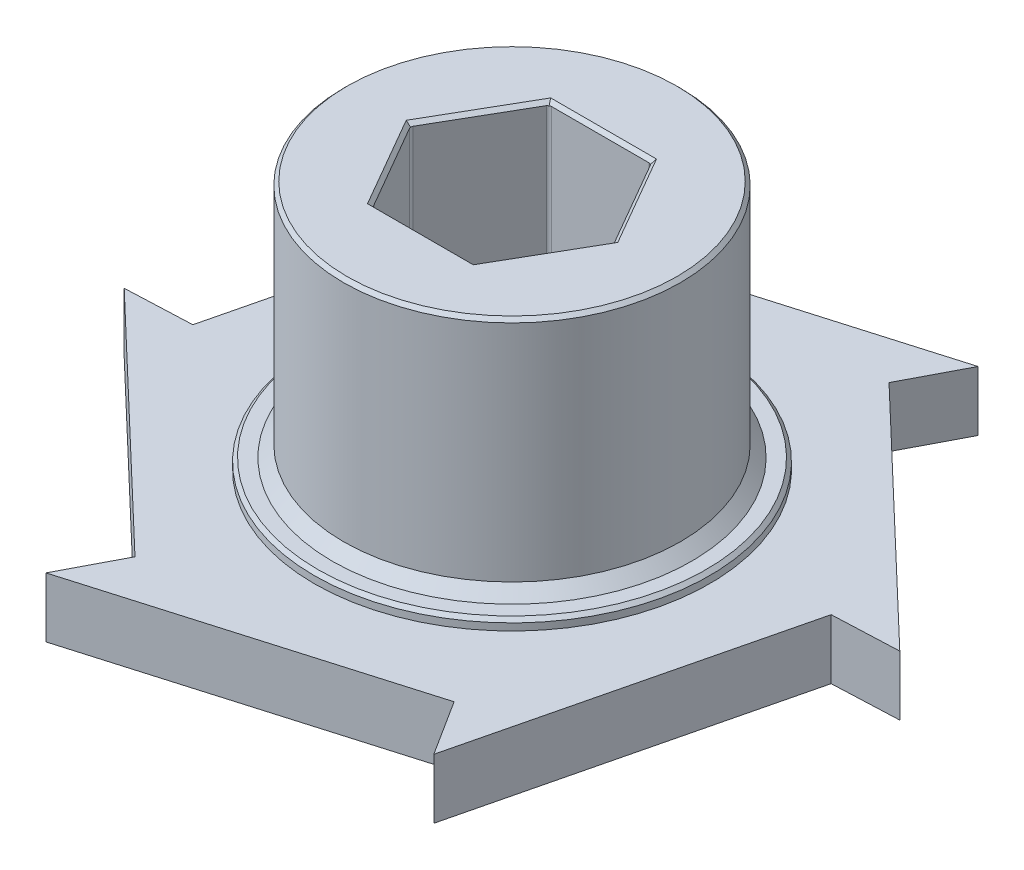
from build123d import *

# Parameters (mm, degrees)
SKETCH1_W           = 27.7876
SKETCH1_H           = 4.318
CUT_EXTRUDE1_DEPTH  = 5.318
CUT_EXTRUDE2_DEPTH  = 5.318
CUT_EXTRUDE3_DEPTH  = 5.318
CUT_EXTRUDE4_DEPTH  = 5.318
CUT_EXTRUDE5_DEPTH  = 5.318
CUT_EXTRUDE6_DEPTH  = 5.318
CUT_EXTRUDE7_DEPTH  = 5.318
CUT_EXTRUDE8_DEPTH  = 5.318
CUT_EXTRUDE9_DEPTH  = 5.318
CUT_EXTRUDE10_DEPTH = 5.318
CUT_EXTRUDE11_DEPTH = 5.318
CUT_EXTRUDE12_DEPTH = 5.318
SKETCH14_R          = 14.2748
BOSS_EXTRUDE1_DEPTH = 1.524
SKETCH15_R          = 9.23823544
BOSS_EXTRUDE2_DEPTH = 1.524
SKETCH16_R          = 14.2748
BOSS_EXTRUDE3_DEPTH = 0.762
SKETCH17_R          = 12.1666
BOSS_EXTRUDE4_DEPTH = 17.272
CUT_EXTRUDE13_DEPTH = 26.4
SKETCH19_W          = 2.5908
SKETCH19_H          = 4.318
SKETCH20_W          = 2.5908
SKETCH20_H          = 4.318
SKETCH21_W          = 2.5908
SKETCH21_H          = 4.318
SKETCH22_W          = 2.5908
SKETCH22_H          = 4.318
SKETCH23_W          = 2.5908
SKETCH23_H          = 4.318
SKETCH24_W          = 2.5908
SKETCH24_H          = 4.318
CHAMFER1_SIZE       = 0.254
CHAMFER2_SIZE       = 0.8128
FILLET1_R           = 0.254
FILLET2_R           = 0.7874
FILLET3_R           = 1.27
SKETCH25_R          = 28.050561638
SKETCH25_R_2        = 25.4889
CUT_EXTRUDE14_DEPTH = 8.366
CUT_EXTRUDE15_DEPTH = 8.366


with BuildPart() as part:
    # Sketch1 → Revolve1 (revolve)
    with BuildSketch(Plane.XY):
        with Locations((13.8938, 5.207)):
            Rectangle(SKETCH1_W, SKETCH1_H)
    revolve(axis=Axis((0, 7.366, 0), (0, -1, 0)))

    # Sketch2 → Cut-Extrude1 (cut, through all)
    with BuildSketch(Plane(origin=(0, 7.366, 0), x_dir=(-1, 0, 0), z_dir=(0, 1, 0))):
        with BuildLine():
            Line((27.742216161, 1.5875), (25.859959008, 1.5875))
            ThreePointArc((25.859959008, 1.5875), (26.4033, 0), (25.859959008, -1.5875))
            Line((25.859959008, -1.5875), (27.742216161, -1.5875))
            ThreePointArc((27.742216161, -1.5875), (27.7876, 0), (27.742216161, 1.5875))
        make_face()
    extrude(amount=-CUT_EXTRUDE1_DEPTH, mode=Mode.SUBTRACT)

    # Sketch3 → Cut-Extrude2 (cut, through all)
    with BuildSketch(Plane(origin=(0, 7.366, 0), x_dir=(-1, 0, 0), z_dir=(0, 1, 0))):
        with BuildLine():
            ThreePointArc((27.521980347, -3.832924674), (26.332306318, -4.701290474), (24.95050128, -5.211190755))
            ThreePointArc((24.95050128, -5.211190755), (22.074034915, -12.74445), (16.988274218, -19.002172568))
            ThreePointArc((16.988274218, -19.002172568), (17.23759014, -20.453800974), (17.080400312, -21.918271806))
            ThreePointArc((17.080400312, -21.918271806), (24.06476751, -13.8938), (27.521980347, -3.832924674))
        make_face()
    extrude(amount=-CUT_EXTRUDE2_DEPTH, mode=Mode.SUBTRACT)

    # Sketch4 → Cut-Extrude3 (cut, through all)
    with BuildSketch(Plane(origin=(0, 7.366, 0), x_dir=(-1, 0, 0), z_dir=(0, 1, 0))):
        with BuildLine():
            Line((15.245923409, -23.231713952), (14.304794833, -21.601631442))
            ThreePointArc((14.304794833, -21.601631442), (13.20165, -22.865928544), (11.555164176, -23.189131442))
            Line((11.555164176, -23.189131442), (12.496292752, -24.819213952))
            ThreePointArc((12.496292752, -24.819213952), (13.8938, -24.06476751), (15.245923409, -23.231713952))
        make_face()
    extrude(amount=-CUT_EXTRUDE3_DEPTH, mode=Mode.SUBTRACT)

    # Sketch5 → Cut-Extrude4 (cut, through all)
    with BuildSketch(Plane(origin=(0, 7.366, 0), x_dir=(-1, 0, 0), z_dir=(0, 1, 0))):
        with BuildLine():
            ThreePointArc((10.441580035, -25.75119648), (9.094716178, -25.155091448), (7.962227062, -24.213363323))
            ThreePointArc((7.962227062, -24.213363323), (0, -25.4889), (-7.962227062, -24.213363323))
            ThreePointArc((-7.962227062, -24.213363323), (-9.094716178, -25.155091448), (-10.441580035, -25.75119648))
            ThreePointArc((-10.441580035, -25.75119648), (0, -27.7876), (10.441580035, -25.75119648))
        make_face()
    extrude(amount=-CUT_EXTRUDE4_DEPTH, mode=Mode.SUBTRACT)

    # Sketch6 → Cut-Extrude5 (cut, through all)
    with BuildSketch(Plane(origin=(0, 7.366, 0), x_dir=(-1, 0, 0), z_dir=(0, 1, 0))):
        with BuildLine():
            Line((-12.496292752, -24.819213952), (-11.555164176, -23.189131442))
            ThreePointArc((-11.555164176, -23.189131442), (-13.20165, -22.865928544), (-14.304794833, -21.601631442))
            Line((-14.304794833, -21.601631442), (-15.245923409, -23.231713952))
            ThreePointArc((-15.245923409, -23.231713952), (-13.8938, -24.06476751), (-12.496292752, -24.819213952))
        make_face()
    extrude(amount=-CUT_EXTRUDE5_DEPTH, mode=Mode.SUBTRACT)

    # Sketch7 → Cut-Extrude6 (cut, through all)
    with BuildSketch(Plane(origin=(0, 7.366, 0), x_dir=(-1, 0, 0), z_dir=(0, 1, 0))):
        with BuildLine():
            ThreePointArc((-17.080400312, -21.918271806), (-17.23759014, -20.453800974), (-16.988274218, -19.002172568))
            ThreePointArc((-16.988274218, -19.002172568), (-22.074034915, -12.74445), (-24.95050128, -5.211190755))
            ThreePointArc((-24.95050128, -5.211190755), (-26.332306318, -4.701290474), (-27.521980347, -3.832924674))
            ThreePointArc((-27.521980347, -3.832924674), (-24.06476751, -13.8938), (-17.080400312, -21.918271806))
        make_face()
    extrude(amount=-CUT_EXTRUDE6_DEPTH, mode=Mode.SUBTRACT)

    # Sketch8 → Cut-Extrude7 (cut, through all)
    with BuildSketch(Plane(origin=(0, 7.366, 0), x_dir=(-1, 0, 0), z_dir=(0, 1, 0))):
        with BuildLine():
            Line((-27.742216161, -1.5875), (-25.859959008, -1.5875))
            ThreePointArc((-25.859959008, -1.5875), (-26.4033, 0), (-25.859959008, 1.5875))
            Line((-25.859959008, 1.5875), (-27.742216161, 1.5875))
            ThreePointArc((-27.742216161, 1.5875), (-27.7876, 0), (-27.742216161, -1.5875))
        make_face()
    extrude(amount=-CUT_EXTRUDE7_DEPTH, mode=Mode.SUBTRACT)

    # Sketch9 → Cut-Extrude8 (cut, through all)
    with BuildSketch(Plane(origin=(0, 7.366, 0), x_dir=(-1, 0, 0), z_dir=(0, 1, 0))):
        with BuildLine():
            ThreePointArc((-27.521980347, 3.832924674), (-26.332306318, 4.701290474), (-24.95050128, 5.211190755))
            ThreePointArc((-24.95050128, 5.211190755), (-22.074034915, 12.74445), (-16.988274218, 19.002172568))
            ThreePointArc((-16.988274218, 19.002172568), (-17.23759014, 20.453800974), (-17.080400312, 21.918271806))
            ThreePointArc((-17.080400312, 21.918271806), (-24.06476751, 13.8938), (-27.521980347, 3.832924674))
        make_face()
    extrude(amount=-CUT_EXTRUDE8_DEPTH, mode=Mode.SUBTRACT)

    # Sketch10 → Cut-Extrude9 (cut, through all)
    with BuildSketch(Plane(origin=(0, 7.366, 0), x_dir=(-1, 0, 0), z_dir=(0, 1, 0))):
        with BuildLine():
            Line((-15.245923409, 23.231713952), (-14.304794833, 21.601631442))
            ThreePointArc((-14.304794833, 21.601631442), (-13.20165, 22.865928544), (-11.555164176, 23.189131442))
            Line((-11.555164176, 23.189131442), (-12.496292752, 24.819213952))
            ThreePointArc((-12.496292752, 24.819213952), (-13.8938, 24.06476751), (-15.245923409, 23.231713952))
        make_face()
    extrude(amount=-CUT_EXTRUDE9_DEPTH, mode=Mode.SUBTRACT)

    # Sketch11 → Cut-Extrude10 (cut, through all)
    with BuildSketch(Plane(origin=(0, 7.366, 0), x_dir=(-1, 0, 0), z_dir=(0, 1, 0))):
        with BuildLine():
            ThreePointArc((-10.441580035, 25.75119648), (-9.094716178, 25.155091448), (-7.962227062, 24.213363323))
            ThreePointArc((-7.962227062, 24.213363323), (0, 25.4889), (7.962227062, 24.213363323))
            ThreePointArc((7.962227062, 24.213363323), (9.094716178, 25.155091448), (10.441580035, 25.75119648))
            ThreePointArc((10.441580035, 25.75119648), (0, 27.7876), (-10.441580035, 25.75119648))
        make_face()
    extrude(amount=-CUT_EXTRUDE10_DEPTH, mode=Mode.SUBTRACT)

    # Sketch12 → Cut-Extrude11 (cut, through all)
    with BuildSketch(Plane(origin=(0, 7.366, 0), x_dir=(-1, 0, 0), z_dir=(0, 1, 0))):
        with BuildLine():
            Line((12.496292752, 24.819213952), (11.555164176, 23.189131442))
            ThreePointArc((11.555164176, 23.189131442), (13.20165, 22.865928544), (14.304794833, 21.601631442))
            Line((14.304794833, 21.601631442), (15.245923409, 23.231713952))
            ThreePointArc((15.245923409, 23.231713952), (13.8938, 24.06476751), (12.496292752, 24.819213952))
        make_face()
    extrude(amount=-CUT_EXTRUDE11_DEPTH, mode=Mode.SUBTRACT)

    # Sketch13 → Cut-Extrude12 (cut, through all)
    with BuildSketch(Plane(origin=(0, 7.366, 0), x_dir=(-1, 0, 0), z_dir=(0, 1, 0))):
        with BuildLine():
            ThreePointArc((17.080400312, 21.918271806), (17.23759014, 20.453800974), (16.988274218, 19.002172568))
            ThreePointArc((16.988274218, 19.002172568), (22.074034915, 12.74445), (24.95050128, 5.211190755))
            ThreePointArc((24.95050128, 5.211190755), (26.332306318, 4.701290474), (27.521980347, 3.832924674))
            ThreePointArc((27.521980347, 3.832924674), (24.06476751, 13.8938), (17.080400312, 21.918271806))
        make_face()
    extrude(amount=-CUT_EXTRUDE12_DEPTH, mode=Mode.SUBTRACT)

    # Sketch14 → Boss-Extrude1 (add)
    with BuildSketch(Plane.XZ.offset(-3.048)):
        Circle(SKETCH14_R)
    extrude(amount=BOSS_EXTRUDE1_DEPTH)

    # Sketch15 → Boss-Extrude2 (add)
    with BuildSketch(Plane.XZ.offset(-1.524)):
        Circle(SKETCH15_R)
    extrude(amount=BOSS_EXTRUDE2_DEPTH)

    # Sketch16 → Boss-Extrude3 (add)
    with BuildSketch(Plane(origin=(0, 7.366, 0), x_dir=(-1, 0, 0), z_dir=(0, 1, 0))):
        Circle(SKETCH16_R)
    extrude(amount=BOSS_EXTRUDE3_DEPTH)

    # Sketch17 → Boss-Extrude4 (add)
    with BuildSketch(Plane(origin=(0, 8.128, 0), x_dir=(-1, 0, 0), z_dir=(0, 1, 0))):
        Circle(SKETCH17_R)
    extrude(amount=BOSS_EXTRUDE4_DEPTH)

    # Sketch18 → Cut-Extrude13 (cut, through all)
    with BuildSketch(Plane(origin=(0, 25.4, 0), x_dir=(-1, 0, 0), z_dir=(0, 1, 0))):
        Polygon((-3.673506558, -6.3627), (3.673506558, -6.3627), (7.347013116, 0), (3.673506558, 6.3627), (-3.673506558, 6.3627), (-7.347013116, 0), align=None)
    extrude(amount=-CUT_EXTRUDE13_DEPTH, mode=Mode.SUBTRACT)

    # Sketch19 → Cut-Revolve1 (revolve, cut)
    with BuildSketch(Plane(origin=(0, 0, 0), x_dir=(-1, 0, 0), z_dir=(0, 0, -1))):
        with Locations((22.5171, 5.207)):
            Rectangle(SKETCH19_W, SKETCH19_H)
    revolve(axis=Axis((-23.8125, 3.048, 0), (0, 1, 0)), mode=Mode.SUBTRACT)

    # Sketch20 → Cut-Revolve2 (revolve, cut)
    with BuildSketch(Plane(origin=(0, 0, -20.622229928), x_dir=(-1, 0, 0), z_dir=(0, 0, -1))):
        with Locations((10.61085, 5.207)):
            Rectangle(SKETCH20_W, SKETCH20_H)
    revolve(axis=Axis((-11.90625, 3.048, -20.622229928), (0, 1, 0)), mode=Mode.SUBTRACT)

    # Sketch21 → Cut-Revolve3 (revolve, cut)
    with BuildSketch(Plane(origin=(0, 0, -20.622229928), x_dir=(-1, 0, 0), z_dir=(0, 0, -1))):
        with Locations((-13.20165, 5.207)):
            Rectangle(SKETCH21_W, SKETCH21_H)
    revolve(axis=Axis((11.90625, 3.048, -20.622229928), (0, 1, 0)), mode=Mode.SUBTRACT)

    # Sketch22 → Cut-Revolve4 (revolve, cut)
    with BuildSketch(Plane(origin=(0, 0, 0), x_dir=(-1, 0, 0), z_dir=(0, 0, -1))):
        with Locations((-25.1079, 5.207)):
            Rectangle(SKETCH22_W, SKETCH22_H)
    revolve(axis=Axis((23.8125, 3.048, 0), (0, 1, 0)), mode=Mode.SUBTRACT)

    # Sketch23 → Cut-Revolve5 (revolve, cut)
    with BuildSketch(Plane(origin=(0, 0, 20.622229928), x_dir=(-1, 0, 0), z_dir=(0, 0, -1))):
        with Locations((-13.20165, 5.207)):
            Rectangle(SKETCH23_W, SKETCH23_H)
    revolve(axis=Axis((11.90625, 3.048, 20.622229928), (0, 1, 0)), mode=Mode.SUBTRACT)

    # Sketch24 → Cut-Revolve6 (revolve, cut)
    with BuildSketch(Plane(origin=(0, 0, 20.622229928), x_dir=(-1, 0, 0), z_dir=(0, 0, -1))):
        with Locations((10.61085, 5.207)):
            Rectangle(SKETCH24_W, SKETCH24_H)
    revolve(axis=Axis((-11.90625, 3.048, 20.622229928), (0, 1, 0)), mode=Mode.SUBTRACT)

    # Chamfer1
    chamfer1_edges = [part.edges().sort_by_distance(p)[0] for p in [
        (-14.2748, 1.524, 0),
        (-9.23823544, 0, 0),
        (14.2748, 8.128, 0),
        (12.1666, 25.4, 0),
        (5.510259837, 0, -3.18135),
        (5.510259837, 0, 3.18135),
        (0, 0, 6.3627),
        (-5.510259837, 0, 3.18135),
        (-5.510259837, 0, -3.18135),
        (0, 0, -6.3627),
        (5.510259837, 25.4, -3.18135),
        (0, 25.4, -6.3627),
        (-5.510259837, 25.4, -3.18135),
        (-5.510259837, 25.4, 3.18135),
        (0, 25.4, 6.3627),
        (5.510259837, 25.4, 3.18135),
    ]]
    chamfer(chamfer1_edges, length=CHAMFER1_SIZE)

    # Chamfer2
    chamfer2_edges = [part.edges().sort_by_distance(p)[0] for p in [
        (12.1666, 8.128, 0),
    ]]
    chamfer(chamfer2_edges, length=CHAMFER2_SIZE)

    # Fillet1
    fillet1_edges = [part.edges().sort_by_distance(p)[0] for p in [
        (3.673506558, 12.7, -6.3627),
        (7.347013116, 12.7, 0),
        (-3.673506558, 12.7, -6.3627),
        (-7.347013116, 12.7, 0),
        (-3.673506558, 12.7, 6.3627),
        (3.673506558, 12.7, 6.3627),
    ]]
    fillet(fillet1_edges, radius=FILLET1_R)

    # Fillet2
    fillet2_edges = [part.edges().sort_by_distance(p)[0] for p in [
        (27.742216161, 5.207, -1.5875),
        (27.742216161, 5.207, 1.5875),
        (25.859959008, 5.207, 1.5875),
        (25.859959008, 5.207, -1.5875),
        (-27.742216161, 5.207, 1.5875),
        (-27.742216161, 5.207, -1.5875),
        (-25.859959008, 5.207, -1.5875),
        (-25.859959008, 5.207, 1.5875),
        (15.245923409, 5.207, 23.231713952),
        (12.496292752, 5.207, 24.819213952),
        (11.555164176, 5.207, 23.189131442),
        (14.304794833, 5.207, 21.601631442),
        (-12.496292752, 5.207, 24.819213952),
        (-15.245923409, 5.207, 23.231713952),
        (-14.304794833, 5.207, 21.601631442),
        (-11.555164176, 5.207, 23.189131442),
        (-15.245923409, 5.207, -23.231713952),
        (-12.496292752, 5.207, -24.819213952),
        (-11.555164176, 5.207, -23.189131442),
        (-14.304794833, 5.207, -21.601631442),
        (12.496292752, 5.207, -24.819213952),
        (15.245923409, 5.207, -23.231713952),
        (14.304794833, 5.207, -21.601631442),
        (11.555164176, 5.207, -23.189131442),
    ]]
    fillet(fillet2_edges, radius=FILLET2_R)

    # Fillet3
    fillet3_edges = [part.edges().sort_by_distance(p)[0] for p in [
        (27.521980347, 5.207, 3.832924674),
        (17.080400312, 5.207, 21.918271806),
        (16.988274218, 5.207, 19.002172568),
        (24.95050128, 5.207, 5.211190755),
        (10.441580035, 5.207, 25.75119648),
        (-10.441580035, 5.207, 25.75119648),
        (-7.962227062, 5.207, 24.213363323),
        (7.962227062, 5.207, 24.213363323),
        (-17.080400312, 5.207, 21.918271806),
        (-27.521980347, 5.207, 3.832924674),
        (-24.95050128, 5.207, 5.211190755),
        (-16.988274218, 5.207, 19.002172568),
        (-27.521980347, 5.207, -3.832924674),
        (-17.080400312, 5.207, -21.918271806),
        (-16.988274218, 5.207, -19.002172568),
        (-24.95050128, 5.207, -5.211190755),
        (-10.441580035, 5.207, -25.75119648),
        (10.441580035, 5.207, -25.75119648),
        (7.962227062, 5.207, -24.213363323),
        (-7.962227062, 5.207, -24.213363323),
        (17.080400312, 5.207, -21.918271806),
        (27.521980347, 5.207, -3.832924674),
        (24.95050128, 5.207, -5.211190755),
        (16.988274218, 5.207, -19.002172568),
    ]]
    fillet(fillet3_edges, radius=FILLET3_R)

    # Sketch25 → Cut-Extrude14 (cut, through all)
    with BuildSketch(Plane(origin=(0, 7.366, 0), x_dir=(1, 0, 0), z_dir=(0, 1, 0))):
        Circle(SKETCH25_R)
        Circle(SKETCH25_R_2, mode=Mode.SUBTRACT)
    extrude(amount=-CUT_EXTRUDE14_DEPTH, mode=Mode.SUBTRACT)

    # Sketch26 → Cut-Extrude15 (cut, through all)
    with BuildSketch(Plane(origin=(0, 7.366, 0), x_dir=(1, 0, 0), z_dir=(0, 1, 0))):
        with BuildLine():
            Line((-14.976810881, 20.624722035), (-12.423898781, 16.604268571))
            Line((-12.423898781, 16.604268571), (10.373127788, 23.282659708))
            ThreePointArc((10.373127788, 23.282659708), (-2.657937673, 25.349938669), (-14.976810881, 20.624722035))
        make_face()
        with BuildLine():
            Line((-20.591667784, -2.457277673), (-14.976810881, 20.624722035))
            ThreePointArc((-14.976810881, 20.624722035), (-23.282659708, 10.373127788), (-25.349938669, -2.657937673))
            Line((-25.349938669, -2.657937673), (-20.591667784, -2.457277673))
        make_face()
        with BuildLine():
            ThreePointArc((25.349938669, 2.657937673), (20.624722035, 14.976810881), (10.373127788, 23.282659708))
            Line((10.373127788, 23.282659708), (8.167769003, 19.061546244))
            Line((8.167769003, 19.061546244), (25.349938669, 2.657937673))
        make_face()
        with BuildLine():
            Line((-8.167769003, -19.061546244), (-25.349938669, -2.657937673))
            ThreePointArc((-25.349938669, -2.657937673), (-20.624722035, -14.976810881), (-10.373127788, -23.282659708))
            Line((-10.373127788, -23.282659708), (-8.167769003, -19.061546244))
        make_face()
        with BuildLine():
            ThreePointArc((14.976810881, -20.624722035), (23.282659708, -10.373127788), (25.349938669, 2.657937673))
            Line((25.349938669, 2.657937673), (20.591667784, 2.457277673))
            Line((20.591667784, 2.457277673), (14.976810881, -20.624722035))
        make_face()
        with BuildLine():
            Line((12.423898781, -16.604268571), (-10.373127788, -23.282659708))
            ThreePointArc((-10.373127788, -23.282659708), (2.657937673, -25.349938669), (14.976810881, -20.624722035))
            Line((14.976810881, -20.624722035), (12.423898781, -16.604268571))
        make_face()
    extrude(amount=-CUT_EXTRUDE15_DEPTH, mode=Mode.SUBTRACT)


solid = part.part
